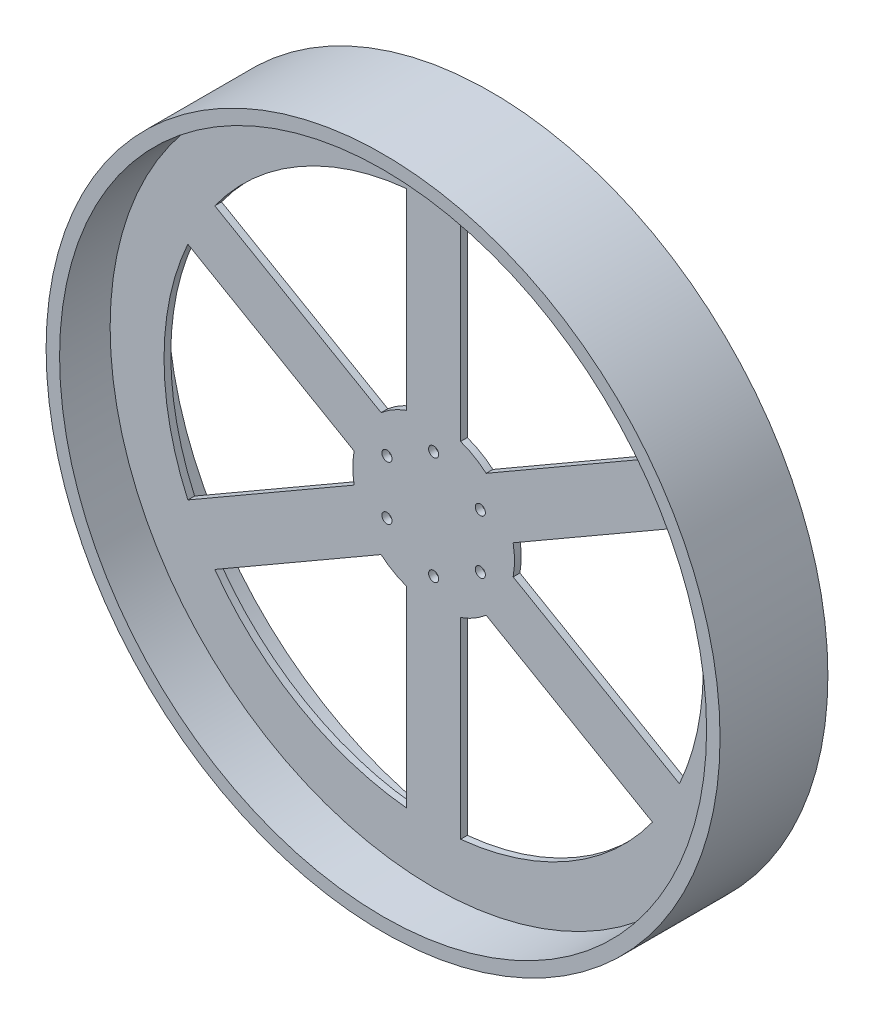
from build123d import *

# Parameters (mm, degrees)
BOSS_EXTRUDE1_DEPTH      = 3.175
BOSS_EXTRUDE1_DEPTH_BACK = 3.175
SKETCH2_R                = 304.8
BOSS_EXTRUDE2_DEPTH      = 50.8
BOSS_EXTRUDE2_DEPTH_BACK = 50.8
SKETCH5_R                = 317.5
SKETCH5_R_2              = 304.8
SKETCH6_R                = 4.7625
CUT_EXTRUDE1_DEPTH       = 453.245288118


with BuildPart() as part:
    # Sketch2 → Boss-Extrude1 (new, two sides: drawn at the far end of the back side and taken through both)
    with BuildSketch(Plane.XY.offset(-BOSS_EXTRUDE1_DEPTH_BACK)):
        Circle(SKETCH2_R)
        with BuildLine():
            ThreePointArc((25.4, -71.842048969), (38.1, -65.991135768), (49.517039467, -57.91806974))
            Line((49.517039467, -57.91806974), (206.167836833, -148.360449769))
            ThreePointArc((206.167836833, -148.360449769), (127, -219.970452561), (25.4, -252.726809025))
            Line((25.4, -252.726809025), (25.4, -71.842048969))
        make_face(mode=Mode.SUBTRACT)
        with BuildLine():
            ThreePointArc((-49.517039467, -57.91806974), (-38.1, -65.991135768), (-25.4, -71.842048969))
            Line((-25.4, -71.842048969), (-25.4, -252.726809025))
            ThreePointArc((-25.4, -252.726809025), (-127, -219.970452561), (-206.167836833, -148.360449769))
            Line((-206.167836833, -148.360449769), (-49.517039467, -57.91806974))
        make_face(mode=Mode.SUBTRACT)
        with BuildLine():
            ThreePointArc((-74.917039467, 13.923979228), (-76.2, 0), (-74.917039467, -13.923979228))
            Line((-74.917039467, -13.923979228), (-231.567836833, -104.366359256))
            ThreePointArc((-231.567836833, -104.366359256), (-254, 0), (-231.567836833, 104.366359256))
            Line((-231.567836833, 104.366359256), (-74.917039467, 13.923979228))
        make_face(mode=Mode.SUBTRACT)
        with BuildLine():
            ThreePointArc((-25.4, 71.842048969), (-38.1, 65.991135768), (-49.517039467, 57.91806974))
            Line((-49.517039467, 57.91806974), (-206.167836833, 148.360449769))
            ThreePointArc((-206.167836833, 148.360449769), (-127, 219.970452561), (-25.4, 252.726809025))
            Line((-25.4, 252.726809025), (-25.4, 71.842048969))
        make_face(mode=Mode.SUBTRACT)
        with BuildLine():
            ThreePointArc((49.517039467, 57.91806974), (38.1, 65.991135768), (25.4, 71.842048969))
            Line((25.4, 71.842048969), (25.4, 252.726809025))
            ThreePointArc((25.4, 252.726809025), (127, 219.970452561), (206.167836833, 148.360449769))
            Line((206.167836833, 148.360449769), (49.517039467, 57.91806974))
        make_face(mode=Mode.SUBTRACT)
        with BuildLine():
            Line((74.917039467, 13.923979228), (231.567836833, 104.366359256))
            ThreePointArc((231.567836833, 104.366359256), (254, 0), (231.567836833, -104.366359256))
            Line((231.567836833, -104.366359256), (74.917039467, -13.923979228))
            ThreePointArc((74.917039467, -13.923979228), (76.2, 0), (74.917039467, 13.923979228))
        make_face(mode=Mode.SUBTRACT)
    extrude(amount=BOSS_EXTRUDE1_DEPTH + BOSS_EXTRUDE1_DEPTH_BACK)

    # Sketch5 → Boss-Extrude2 (add, two sides: drawn at the far end of the back side and taken through both)
    with BuildSketch(Plane.XY.offset(-BOSS_EXTRUDE2_DEPTH_BACK)):
        Circle(SKETCH5_R)
        Circle(SKETCH5_R_2, mode=Mode.SUBTRACT)
    extrude(amount=BOSS_EXTRUDE2_DEPTH + BOSS_EXTRUDE2_DEPTH_BACK)

    # Sketch6 → Cut-Extrude1 (cut, through all)
    with BuildSketch(Plane.XY.offset(3.175)):
        with Locations((0, 50.8)):
            Circle(SKETCH6_R)
        with Locations((43.994090512, 25.4)):
            Circle(SKETCH6_R)
        with Locations((43.994090512, -25.4)):
            Circle(SKETCH6_R)
        with Locations((0, -50.8)):
            Circle(SKETCH6_R)
        with Locations((-43.994090512, -25.4)):
            Circle(SKETCH6_R)
        with Locations((-43.994090512, 25.4)):
            Circle(SKETCH6_R)
    extrude(amount=-CUT_EXTRUDE1_DEPTH, mode=Mode.SUBTRACT)


solid = part.part
